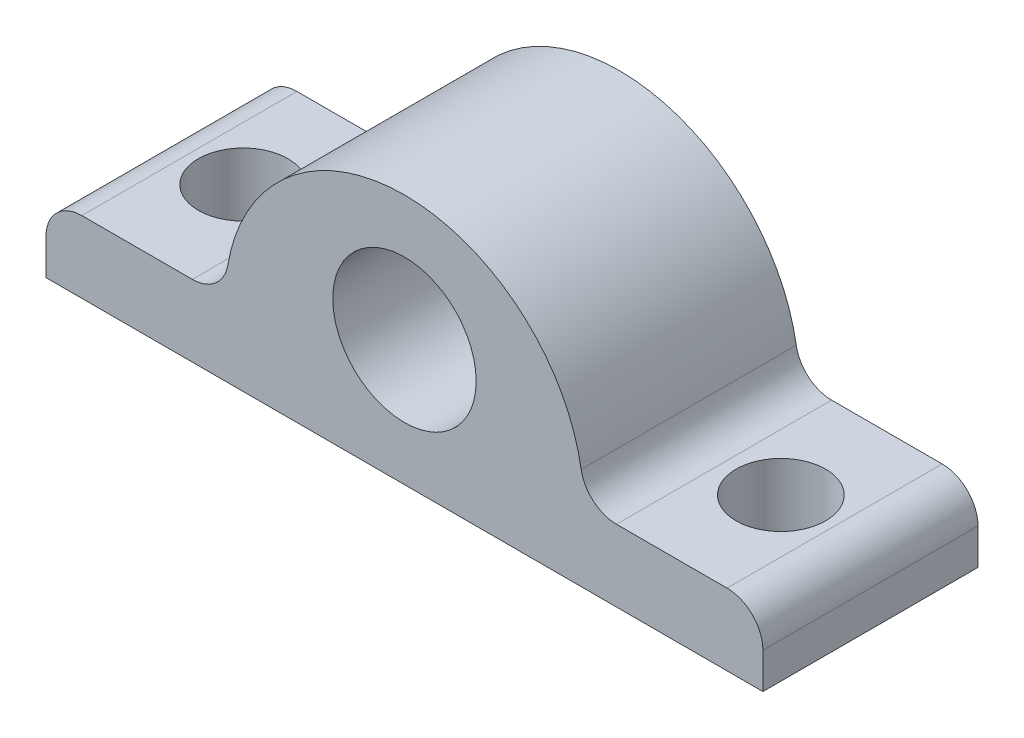
from build123d import *

# Parameters (mm, degrees)
SKETCH1_W           = 40
SKETCH1_H           = 12
BOSS_EXTRUDE1_DEPTH = 4
BOSS_EXTRUDE2_DEPTH = 12
SKETCH3_R           = 4
CUT_EXTRUDE1_DEPTH  = 13
SKETCH4_R           = 2.5
CUT_EXTRUDE2_DEPTH  = 5
FILLET1_R           = 2


with BuildPart() as part:
    # Sketch1 → Boss-Extrude1 (new body)
    with BuildSketch(Plane(origin=(0, 0, 0), x_dir=(1, 0, 0), z_dir=(0, 1, 0))):
        Rectangle(SKETCH1_W, SKETCH1_H)
    extrude(amount=BOSS_EXTRUDE1_DEPTH)

    # Sketch2 → Boss-Extrude2 (add)
    with BuildSketch(Plane.XY.offset(6)):
        with BuildLine():
            Line((20, 4), (10, 4))
            ThreePointArc((10, 4), (0, 14), (-10, 4))
            Line((-10, 4), (-20, 4))
            Line((-20, 4), (-20, 0))
            Line((-20, 0), (20, 0))
            Line((20, 0), (20, 4))
        make_face()
    extrude(amount=-BOSS_EXTRUDE2_DEPTH)

    # Sketch3 → Cut-Extrude1 (cut, through all)
    with BuildSketch(Plane.XY.offset(6)):
        with Locations((0, 7)):
            Circle(SKETCH3_R)
    extrude(amount=-CUT_EXTRUDE1_DEPTH, mode=Mode.SUBTRACT)

    # Sketch4 → Cut-Extrude2 (cut, through all)
    with BuildSketch(Plane(origin=(0, 4, 0), x_dir=(1, 0, 0), z_dir=(0, 1, 0))):
        with Locations((-15, 0)):
            Circle(SKETCH4_R)
        with Locations((15, 0)):
            Circle(SKETCH4_R)
    extrude(amount=-CUT_EXTRUDE2_DEPTH, mode=Mode.SUBTRACT)

    # Fillet1
    fillet1_edges = [part.edges().sort_by_distance(p)[0] for p in [
        (-20, 4, 0),
        (-10, 4, 0),
        (10, 4, 0),
        (20, 4, 0),
    ]]
    fillet(fillet1_edges, radius=FILLET1_R)


solid = part.part
